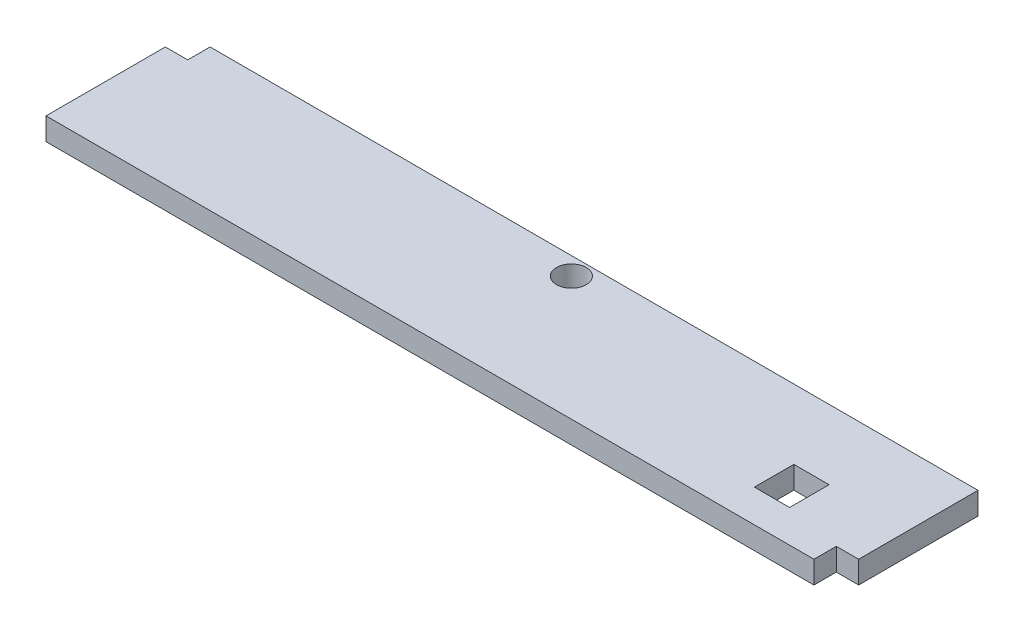
from build123d import *

# Parameters (mm, degrees)
SKETCH1_W           = 673.1
SKETCH1_H           = 120.7008
BOSS_EXTRUDE1_DEPTH = 19.05
SKETCH3_W           = 30.013638179
SKETCH3_H           = 33.61527476
CUT_EXTRUDE5_DEPTH  = 20.05
SKETCH2_R           = 12.7
CUT_EXTRUDE4_DEPTH  = 20.05
SKETCH4_W           = 19.05
SKETCH4_H           = 19.05
CUT_EXTRUDE6_DEPTH  = 20.05


with BuildPart() as part:
    # Sketch1 → Boss-Extrude1 (new body)
    with BuildSketch(Plane(origin=(0, 0, 0), x_dir=(1, 0, 0), z_dir=(0, 1, 0))):
        with Locations((336.55, 60.3504)):
            Rectangle(SKETCH1_W, SKETCH1_H)
    extrude(amount=BOSS_EXTRUDE1_DEPTH)

    # Sketch3 → Cut-Extrude5 (cut, through all)
    with BuildSketch(Plane.XZ):
        with Locations((590.529823595, -44.616403279)):
            Rectangle(SKETCH3_W, SKETCH3_H)
    extrude(amount=-CUT_EXTRUDE5_DEPTH, mode=Mode.SUBTRACT)

    # Sketch2 → Cut-Extrude4 (cut, through all)
    with BuildSketch(Plane.XZ):
        with Locations((341.9094, -105.5624)):
            Circle(SKETCH2_R)
    extrude(amount=-CUT_EXTRUDE4_DEPTH, mode=Mode.SUBTRACT)

    # Sketch4 → Cut-Extrude6 (cut, through all)
    with BuildSketch(Plane.XZ):
        with Locations((663.575, -9.525)):
            Rectangle(SKETCH4_W, SKETCH4_H)
        with Locations((9.525, -111.1758)):
            Rectangle(SKETCH4_W, SKETCH4_H)
    extrude(amount=-CUT_EXTRUDE6_DEPTH, mode=Mode.SUBTRACT)


solid = part.part
